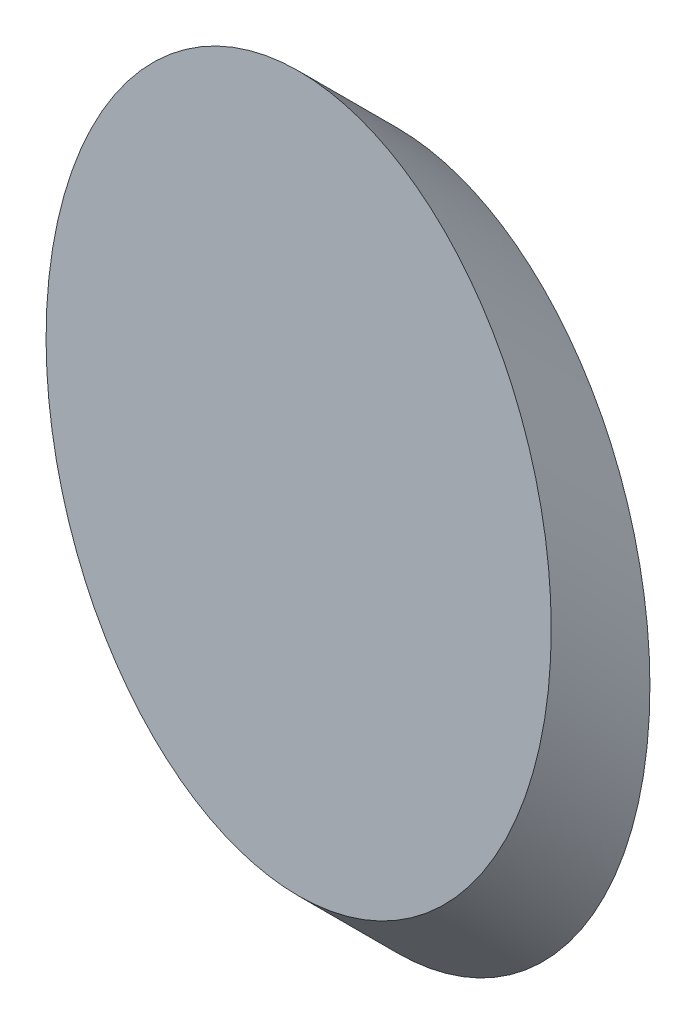
from build123d import *

# Parameters (mm, degrees)
SKETCH_1_RX     = 45.26
SKETCH_1_RY     = 32
EXTRUDE_2_DEPTH = 17.68


with BuildPart() as part:
    # 草图1 → 凸台-拉伸2 (new body, along a direction that is not the sketch's normal)
    with BuildSketch(Plane.XY):
        with Locations(Location((54.392382982, 35.78887153), (0, 0, 90))):
            Ellipse(SKETCH_1_RX, SKETCH_1_RY)
    extrude(amount=EXTRUDE_2_DEPTH, dir=(0, 0.707106781, 0.707106781))


solid = part.part
